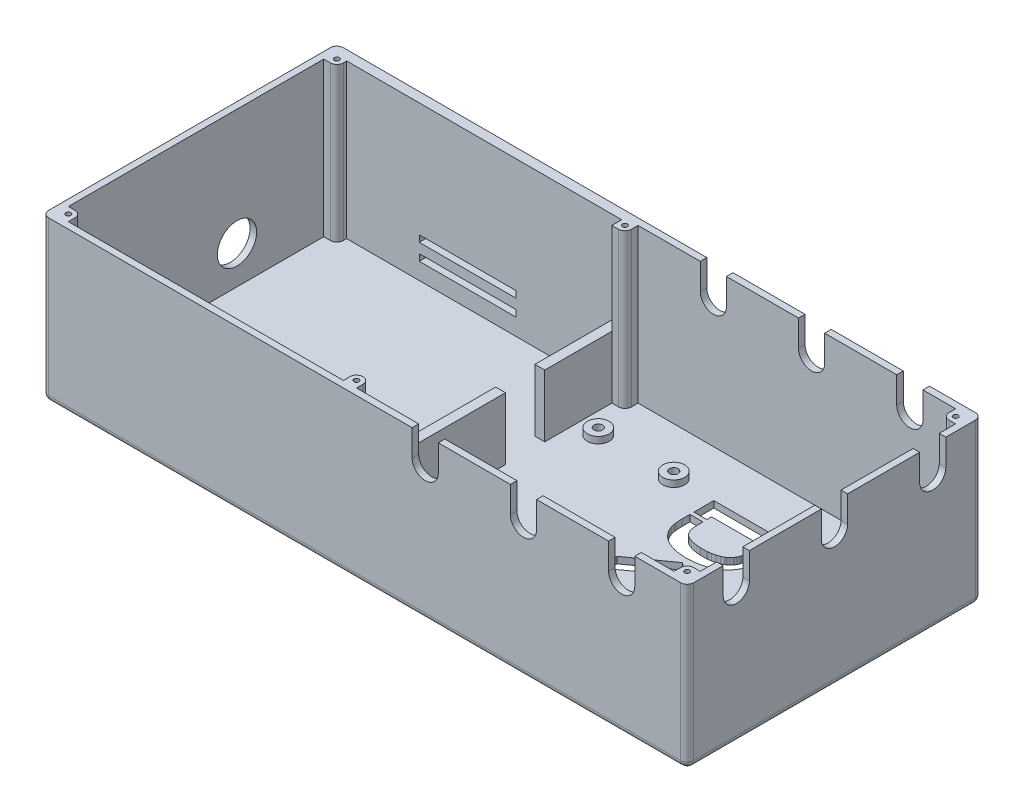
from build123d import *

# Parameters (mm, degrees)
SKETCH2_W               = 197
SKETCH2_H               = 90
BOSS_EXTRUDE1_DEPTH     = 21
SHELL1_T                = -2
SKETCH3_R               = 3.325
SKETCH3_R_2             = 1.325
BOSS_EXTRUDE2_DEPTH     = 2
SKETCH6_R               = 1.325
CUT_EXTRUDE2_DEPTH      = 3
BOSS_EXTRUDE3_DEPTH     = 19
SKETCH10_W              = 3
SKETCH10_H              = 12
CUT_EXTRUDE5_DEPTH      = 19
SKETCH12_W              = 29.592043876
SKETCH12_H              = 2
CUT_EXTRUDE6_DEPTH      = 67.044155007
CUT_EXTRUDE6_DEPTH_BACK = 73
CUT_EXTRUDE8_DEPTH      = 10
FILLET1_R               = 2
SKETCH7_R               = 6
CUT_EXTRUDE9_DEPTH      = 10
BOSS_EXTRUDE4_DEPTH     = 24
SKETCH18_W              = 191
SKETCH18_H              = 84
CUT_EXTRUDE10_DEPTH     = 21
BOSS_EXTRUDE5_DEPTH     = 19
SKETCH22_R              = 0.75
CUT_EXTRUDE11_DEPTH     = 44
SKETCH23_R              = 2
CUT_EXTRUDE12_DEPTH     = 22
SKETCH24_W              = 197
SKETCH24_H              = 24
CUT_EXTRUDE13_DEPTH     = 91
SKETCH25_R              = 0.75
BOSS_EXTRUDE9_DEPTH     = 28
BOSS_EXTRUDE10_START    = -2
BOSS_EXTRUDE10_DEPTH    = 2
BOSS_EXTRUDE11_DEPTH    = 30
SKETCH28_W              = 191
SKETCH28_H              = 84
CUT_EXTRUDE14_DEPTH     = 27
SKETCH29_R              = 0.75
CUT_EXTRUDE15_DEPTH     = 78
SKETCH30_W              = 197
SKETCH30_H              = 30
CUT_EXTRUDE16_DEPTH     = 91
CUT_EXTRUDE17_DEPTH     = 10
CUT_EXTRUDE18_DEPTH     = 91
CUT_EXTRUDE19_DEPTH     = 10


with BuildPart() as part:
    # Sketch2 → Boss-Extrude1 (new body)
    with BuildSketch(Plane(origin=(0, 0, 0), x_dir=(1, 0, 0), z_dir=(0, 1, 0))):
        with Locations((98.5, 45)):
            Rectangle(SKETCH2_W, SKETCH2_H)
    extrude(amount=BOSS_EXTRUDE1_DEPTH)

    # Shell1
    shell1_openings = [part.faces().sort_by_distance(p)[0] for p in [
        (98.5, 21, -45),
    ]]
    offset(amount=SHELL1_T, openings=shell1_openings, kind=Kind.INTERSECTION)

    # Sketch3 → Boss-Extrude2 (add)
    with BuildSketch(Plane(origin=(0.486650368, 2, 38.670182975), x_dir=(1, 0, 0), z_dir=(0, 1, 0))):
        with Locations((118.948969004, 54.089521182)):
            Circle(SKETCH3_R)
        with Locations((118.948969004, 54.089521182)):
            Circle(SKETCH3_R_2, mode=Mode.SUBTRACT)
        with Locations((95.898969004, 54.089521182)):
            Circle(SKETCH3_R)
        with Locations((95.898969004, 54.089521182)):
            Circle(SKETCH3_R_2, mode=Mode.SUBTRACT)
        with Locations((95.898969004, 112.139521182)):
            Circle(SKETCH3_R)
        with Locations((95.898969004, 112.139521182)):
            Circle(SKETCH3_R_2, mode=Mode.SUBTRACT)
        with Locations((118.948969004, 112.139521182)):
            Circle(SKETCH3_R)
        with Locations((118.948969004, 112.139521182)):
            Circle(SKETCH3_R_2, mode=Mode.SUBTRACT)
    extrude(amount=BOSS_EXTRUDE2_DEPTH)

    # Sketch6 → Cut-Extrude2 (cut, through all)
    with BuildSketch(Plane(origin=(0, 2, 0), x_dir=(1, 0, 0), z_dir=(0, 1, 0))):
        with Locations((96.385619372, 73.469338207)):
            Circle(SKETCH6_R)
        with Locations((119.435619372, 73.469338207)):
            Circle(SKETCH6_R)
        with Locations((119.435619372, 15.419338207)):
            Circle(SKETCH6_R)
        with Locations((96.385619372, 15.419338207)):
            Circle(SKETCH6_R)
    extrude(amount=-CUT_EXTRUDE2_DEPTH, mode=Mode.SUBTRACT)

    # Sketch8 → Boss-Extrude3 (add)
    with BuildSketch(Plane(origin=(0, 2, 0), x_dir=(1, 0, 0), z_dir=(0, 1, 0))):
        Polygon((2, 28), (87, 28), (87, 87), (2, 87), (2, 90), (90, 90), (90, 25), (2, 25), align=None)
    extrude(amount=BOSS_EXTRUDE3_DEPTH)

    # Sketch10 → Cut-Extrude5 (cut)
    with BuildSketch(Plane(origin=(0, 21, 0), x_dir=(1, 0, 0), z_dir=(0, 1, 0))):
        with Locations((88.5, 57.5)):
            Rectangle(SKETCH10_W, SKETCH10_H)
    extrude(amount=-CUT_EXTRUDE5_DEPTH, mode=Mode.SUBTRACT)

    # Sketch12 → Cut-Extrude6 (cut, two sides)
    with BuildSketch(Plane(origin=(0, 0, -75), x_dir=(-1, 0, 0), z_dir=(0, 0, -1))) as cut_extrude6_sk:
        with Locations((-42.979341868, 13.109706)):
            Rectangle(SKETCH12_W, SKETCH12_H)
        with Locations((-42.979341868, 8.109706)):
            Rectangle(SKETCH12_W, SKETCH12_H)
    extrude(amount=CUT_EXTRUDE6_DEPTH, mode=Mode.SUBTRACT)
    extrude(cut_extrude6_sk.sketch, amount=-CUT_EXTRUDE6_DEPTH_BACK, mode=Mode.SUBTRACT)

    # Sketch16 → Cut-Extrude8 (cut)
    with BuildSketch(Plane(origin=(197, 0, 0), x_dir=(0, 0, -1), z_dir=(1, 0, 0))):
        with BuildLine():
            Line((48, 14.235547834), (48, 21))
            Line((48, 21), (42, 21))
            Line((42, 21), (42, 14.235547834))
            ThreePointArc((42, 14.235547834), (45, 11.235547834), (48, 14.235547834))
        make_face()
    extrude(amount=-CUT_EXTRUDE8_DEPTH, mode=Mode.SUBTRACT)

    # Fillet1
    fillet1_edges = [part.edges().sort_by_distance(p)[0] for p in [
        (98.5, 0, -90),
        (197, 0, -45),
        (98.5, 0, 0),
        (0, 0, -45),
        (0, 10.5, -90),
        (197, 10.5, -90),
        (197, 10.5, 0),
        (0, 10.5, 0),
    ]]
    fillet(fillet1_edges, radius=FILLET1_R)

    # Sketch7 → Cut-Extrude9 (cut)
    with BuildSketch(Plane.ZY):
        with Locations((-57.5, 13.5)):
            Circle(SKETCH7_R)
    extrude(amount=-CUT_EXTRUDE9_DEPTH, mode=Mode.SUBTRACT)

    # Sketch17 → Boss-Extrude4 (add)
    with BuildSketch(Plane(origin=(0, 21, 0), x_dir=(1, 0, 0), z_dir=(0, 1, 0))):
        with BuildLine():
            Line((197, 48), (197, 42))
            Line((197, 42), (197, 2))
            ThreePointArc((197, 2), (196.414213562, 0.585786438), (195, 0))
            Line((195, 0), (2, 0))
            ThreePointArc((2, 0), (0.585786438, 0.585786438), (0, 2))
            Line((0, 2), (0, 88))
            ThreePointArc((0, 88), (0.585786438, 89.414213562), (2, 90))
            Line((2, 90), (195, 90))
            ThreePointArc((195, 90), (196.414213562, 89.414213562), (197, 88))
            Line((197, 88), (197, 48))
        make_face()
    extrude(amount=BOSS_EXTRUDE4_DEPTH)

    # Sketch18 → Cut-Extrude10 (cut)
    with BuildSketch(Plane(origin=(0, 45, 0), x_dir=(1, 0, 0), z_dir=(0, 1, 0))):
        with Locations((98.5, 45)):
            Rectangle(SKETCH18_W, SKETCH18_H)
    extrude(amount=-CUT_EXTRUDE10_DEPTH, mode=Mode.SUBTRACT)

    # Sketch19 → Boss-Extrude5 (add)
    with BuildSketch(Plane(origin=(0, 2, 0), x_dir=(1, 0, 0), z_dir=(0, 1, 0))):
        with BuildLine():
            Line((193, 88), (195, 88))
            Line((195, 88), (195, 84))
            Line((195, 84), (193, 84))
            ThreePointArc((193, 84), (191.585786438, 84.585786438), (191, 86))
            Line((191, 86), (191, 88))
            Line((191, 88), (193, 88))
        make_face()
        with BuildLine():
            Line((191, 2), (193, 2))
            Line((193, 2), (195, 2))
            Line((195, 2), (195, 6))
            Line((195, 6), (193, 6))
            ThreePointArc((193, 6), (191.585786438, 5.414213562), (191, 4))
            Line((191, 4), (191, 2))
        make_face()
        with BuildLine():
            Line((94, 4), (94, 2))
            Line((94, 2), (90, 2))
            Line((90, 2), (90, 4))
            ThreePointArc((90, 4), (92, 6), (94, 4))
        make_face()
        with BuildLine():
            Line((92, 84), (90, 84))
            Line((90, 84), (90, 88))
            Line((90, 88), (94, 88))
            Line((94, 88), (94, 86))
            ThreePointArc((94, 86), (93.414213562, 84.585786438), (92, 84))
        make_face()
        with BuildLine():
            Line((2, 88), (2, 84))
            Line((2, 84), (4, 84))
            ThreePointArc((4, 84), (5.414213562, 84.585786438), (6, 86))
            Line((6, 86), (6, 88))
            Line((6, 88), (2, 88))
        make_face()
        with BuildLine():
            Line((6, 4), (6, 2))
            Line((6, 2), (2, 2))
            Line((2, 2), (2, 6))
            Line((2, 6), (4, 6))
            ThreePointArc((4, 6), (5.414213562, 5.414213562), (6, 4))
        make_face()
    extrude(amount=BOSS_EXTRUDE5_DEPTH)

    # Sketch22 → Cut-Extrude11 (cut, through all)
    with BuildSketch(Plane(origin=(0, 2, 0), x_dir=(1, 0, 0), z_dir=(0, 1, 0))):
        with Locations((4, 4)):
            Circle(SKETCH22_R)
        with Locations((4, 86)):
            Circle(SKETCH22_R)
        with Locations((92, 86)):
            Circle(SKETCH22_R)
        with Locations((193, 86)):
            Circle(SKETCH22_R)
        with Locations((193, 4)):
            Circle(SKETCH22_R)
        with Locations((92, 4)):
            Circle(SKETCH22_R)
    extrude(amount=CUT_EXTRUDE11_DEPTH, mode=Mode.SUBTRACT)

    # Sketch23 → Cut-Extrude12 (cut, through all)
    with BuildSketch(Plane(origin=(0, 24, 0), x_dir=(1, 0, 0), z_dir=(0, 1, 0))):
        with Locations((92, 4)):
            Circle(SKETCH23_R)
        with Locations((4, 4)):
            Circle(SKETCH23_R)
        with Locations((4, 86)):
            Circle(SKETCH23_R)
        with Locations((92, 86)):
            Circle(SKETCH23_R)
        with Locations((193, 86)):
            Circle(SKETCH23_R)
        with Locations((181, 4)):
            Circle(SKETCH23_R)
    extrude(amount=CUT_EXTRUDE12_DEPTH, mode=Mode.SUBTRACT)

    # Sketch24 → Cut-Extrude13 (cut, through all)
    with BuildSketch(Plane.XY):
        with Locations((98.5, 33)):
            Rectangle(SKETCH24_W, SKETCH24_H)
    extrude(amount=-CUT_EXTRUDE13_DEPTH, mode=Mode.SUBTRACT)

    # Sketch25 → Boss-Extrude9 (add)
    with BuildSketch(Plane(origin=(0, 21, 0), x_dir=(1, 0, 0), z_dir=(0, 1, 0))):
        with BuildLine():
            Line((197, 42), (197, 48))
            Line((197, 48), (197, 88))
            ThreePointArc((197, 88), (196.414213562, 89.414213562), (195, 90))
            Line((195, 90), (2, 90))
            ThreePointArc((2, 90), (0.585786438, 89.414213562), (0, 88))
            Line((0, 88), (0, 2))
            ThreePointArc((0, 2), (0.585786438, 0.585786438), (2, 0))
            Line((2, 0), (195, 0))
            ThreePointArc((195, 0), (196.414213562, 0.585786438), (197, 2))
            Line((197, 2), (197, 42))
        make_face()
        with Locations((4, 4)):
            Circle(SKETCH25_R, mode=Mode.SUBTRACT)
        with Locations((4, 86)):
            Circle(SKETCH25_R, mode=Mode.SUBTRACT)
        with Locations((92, 86)):
            Circle(SKETCH25_R, mode=Mode.SUBTRACT)
        with Locations((193, 86)):
            Circle(SKETCH25_R, mode=Mode.SUBTRACT)
        with Locations((193, 4)):
            Circle(SKETCH25_R, mode=Mode.SUBTRACT)
        with Locations((92, 4)):
            Circle(SKETCH25_R, mode=Mode.SUBTRACT)
        with BuildLine():
            Line((2, 25), (2, 28))
            Line((2, 28), (2, 84))
            Line((2, 84), (4, 84))
            ThreePointArc((4, 84), (5.414213562, 84.585786438), (6, 86))
            Line((6, 86), (6, 87))
            Line((6, 87), (87, 87))
            Line((87, 87), (90, 87))
            Line((90, 87), (90, 84))
            Line((90, 84), (92, 84))
            ThreePointArc((92, 84), (93.414213562, 84.585786438), (94, 86))
            Line((94, 86), (94, 88))
            Line((94, 88), (191, 88))
            Line((191, 88), (191, 86))
            ThreePointArc((191, 86), (191.585786438, 84.585786438), (193, 84))
            Line((193, 84), (195, 84))
            Line((195, 84), (195, 48))
            Line((195, 48), (195, 42))
            Line((195, 42), (195, 6))
            Line((195, 6), (193, 6))
            ThreePointArc((193, 6), (191.585786438, 5.414213562), (191, 4))
            Line((191, 4), (191, 2))
            Line((191, 2), (94, 2))
            Line((94, 2), (94, 4))
            ThreePointArc((94, 4), (92, 6), (90, 4))
            Line((90, 4), (90, 2))
            Line((90, 2), (6, 2))
            Line((6, 2), (6, 4))
            ThreePointArc((6, 4), (5.414213562, 5.414213562), (4, 6))
            Line((4, 6), (2, 6))
            Line((2, 6), (2, 25))
        make_face(mode=Mode.SUBTRACT)
    extrude(amount=BOSS_EXTRUDE9_DEPTH)

    # Sketch26 → Boss-Extrude10 (add)
    with BuildSketch(Plane(origin=(197, 0, 0), x_dir=(0, 0, -1), z_dir=(1, 0, 0)).offset(BOSS_EXTRUDE10_START)):
        with BuildLine():
            Line((48, 21), (42, 21))
            Line((42, 21), (42, 14.235547834))
            ThreePointArc((42, 14.235547834), (45, 11.235547834), (48, 14.235547834))
            Line((48, 14.235547834), (48, 21))
        make_face()
    extrude(amount=BOSS_EXTRUDE10_DEPTH)

    # Sketch27 → Boss-Extrude11 (add)
    with BuildSketch(Plane(origin=(0, 49, 0), x_dir=(1, 0, 0), z_dir=(0, 1, 0))):
        with BuildLine():
            Line((197, 2), (197, 88))
            ThreePointArc((197, 88), (196.414213562, 89.414213562), (195, 90))
            Line((195, 90), (2, 90))
            ThreePointArc((2, 90), (0.585786438, 89.414213562), (0, 88))
            Line((0, 88), (0, 2))
            ThreePointArc((0, 2), (0.585786438, 0.585786438), (2, 0))
            Line((2, 0), (195, 0))
            ThreePointArc((195, 0), (196.414213562, 0.585786438), (197, 2))
        make_face()
    extrude(amount=BOSS_EXTRUDE11_DEPTH)

    # Sketch28 → Cut-Extrude14 (cut)
    with BuildSketch(Plane(origin=(0, 79, 0), x_dir=(1, 0, 0), z_dir=(0, 1, 0))):
        with Locations((98.5, 45)):
            Rectangle(SKETCH28_W, SKETCH28_H)
    extrude(amount=-CUT_EXTRUDE14_DEPTH, mode=Mode.SUBTRACT)

    # Sketch29 → Cut-Extrude15 (cut, through all)
    with BuildSketch(Plane(origin=(0, 2, 0), x_dir=(1, 0, 0), z_dir=(0, 1, 0))):
        with Locations((4, 4)):
            Circle(SKETCH29_R)
        with Locations((4, 86)):
            Circle(SKETCH29_R)
        with Locations((193, 86)):
            Circle(SKETCH29_R)
        with Locations((193, 4)):
            Circle(SKETCH29_R)
        with Locations((92, 4)):
            Circle(SKETCH29_R)
        with Locations((92, 86)):
            Circle(SKETCH29_R)
    extrude(amount=CUT_EXTRUDE15_DEPTH, mode=Mode.SUBTRACT)

    # Sketch30 → Cut-Extrude16 (cut, through all)
    with BuildSketch(Plane.XY):
        with Locations((98.5, 64)):
            Rectangle(SKETCH30_W, SKETCH30_H)
    extrude(amount=-CUT_EXTRUDE16_DEPTH, mode=Mode.SUBTRACT)

    # Sketch31 → Cut-Extrude17 (cut)
    with BuildSketch(Plane(origin=(197, 0, 0), x_dir=(0, 0, -1), z_dir=(1, 0, 0))):
        with BuildLine():
            Line((11, 41), (11, 49))
            Line((11, 49), (19, 49))
            Line((19, 49), (19, 41))
            ThreePointArc((19, 41), (15, 37), (11, 41))
        make_face()
        with BuildLine():
            Line((41, 41), (41, 49))
            Line((41, 49), (49, 49))
            Line((49, 49), (49, 41))
            ThreePointArc((49, 41), (45, 37), (41, 41))
        make_face()
        with BuildLine():
            Line((71, 41), (71, 49))
            Line((71, 49), (79, 49))
            Line((79, 49), (79, 41))
            ThreePointArc((79, 41), (75, 37), (71, 41))
        make_face()
    extrude(amount=-CUT_EXTRUDE17_DEPTH, mode=Mode.SUBTRACT)

    # Sketch32 → Cut-Extrude18 (cut, through all)
    with BuildSketch(Plane(origin=(0, 0, -90), x_dir=(-1, 0, 0), z_dir=(0, 0, -1))):
        with BuildLine():
            Line((-181, 41), (-181, 49))
            Line((-181, 49), (-173, 49))
            Line((-173, 49), (-173, 41))
            ThreePointArc((-173, 41), (-177, 37), (-181, 41))
        make_face()
        with BuildLine():
            Line((-151, 41), (-151, 49))
            Line((-151, 49), (-143, 49))
            Line((-143, 49), (-143, 41))
            ThreePointArc((-143, 41), (-147, 37), (-151, 41))
        make_face()
        with BuildLine():
            Line((-121, 41), (-121, 49))
            Line((-121, 49), (-113, 49))
            Line((-113, 49), (-113, 41))
            ThreePointArc((-113, 41), (-117, 37), (-121, 41))
        make_face()
    extrude(amount=-CUT_EXTRUDE18_DEPTH, mode=Mode.SUBTRACT)

    # Sketch33 → Cut-Extrude19 (cut)
    with BuildSketch(Plane.XZ):
        Polygon((131.342069702, -73.803675328), (154.299866313, -73.803675328), (154.299710305, -67.699378511), (150.316474948, -67.699480311), (150.316313825, -69.149681439), (135.319235293, -69.147777765), (135.319198289, -67.699863597), (131.341230491, -67.699965262), align=None)
        Polygon((131.341196563, -66.484557272), (135.319260846, -66.484557272), (135.34368408, -64.448057478), (135.366792102, -63.9318726), (135.560848598, -62.708661438), (135.682097263, -62.30423458), (135.893678175, -61.80665932), (136.275241305, -61.197101423), (136.768517085, -60.67728932), (137.206412644, -60.358311251), (137.3654264, -60.27696896), (137.619460466, -60.141314863), (138.429329253, -59.821544458), (139.54711523, -59.528585895), (140.695070485, -59.357991654), (141.560104111, -59.285015115), (141.848980484, -59.270014756), (142.00799298, -59.272040737), (142.805194033, -59.265085002), (143.60096036, -59.290522135), (143.759711846, -59.308402947), (144.050981541, -59.329738361), (144.921754504, -59.443760306), (146.067309513, -59.694935945), (147.169553693, -60.084590402), (147.605365412, -60.302115943), (147.957226718, -60.477739539), (148.201945322, -60.636173155), (148.373464392, -60.746984895), (148.849657075, -61.139866676), (149.399162726, -61.749166962), (149.829282509, -62.446458977), (150.066552209, -63.017081808), (150.164389322, -63.370649856), (150.286428528, -64.169287648), (150.317606227, -64.978301492), (150.317340242, -65.139921721), (150.317022102, -65.474177119), (150.316844778, -66.484742951), (154.299866306, -66.484742951), (154.306130009, -63.827777621), (154.309097575, -63.683201339), (154.306130009, -63.623229381), (154.268936568, -62.871581975), (154.116406448, -61.799026946), (153.840444811, -60.752175467), (153.552327203, -59.991431467), (153.435112316, -59.74815528), (153.342480786, -59.558502461), (153.021810637, -59.010084781), (152.530520674, -58.321492203), (151.968210602, -57.68908415), (151.505505487, -57.253614431), (151.341853839, -57.119984458), (151.141228331, -56.954918185), (150.503388934, -56.503551752), (149.605979523, -55.976290307), (148.663300078, -55.532707499), (147.935082309, -55.248985177), (147.688602595, -55.166804833), (147.604867631, -55.139298477), (147.350303253, -55.055675841), (146.313807779, -54.788724896), (144.910815347, -54.539325507), (143.490748225, -54.407398012), (142.421835999, -54.374506132), (141.873394291, -54.376795695), (140.474075853, -54.480053515), (139.960962127, -54.536392347), (139.679215442, -54.574485676), (138.769173961, -54.740147845), (138.678843121, -54.759836004), (138.345808129, -54.826175974), (137.364112179, -55.111912445), (136.106036197, -55.63316624), (134.930157627, -56.318115995), (134.112525325, -56.932308332), (133.862219717, -57.161228166), (133.621489595, -57.382596091), (132.982823964, -58.13649352), (132.29180869, -59.251135395), (131.797688048, -60.467712388), (131.554081629, -61.424515204), (131.497799571, -61.801701219), (131.409218501, -62.50048484), (131.341071393, -64.081483142), align=None)
        Polygon((142.953556674, -52.556580272), (154.299866306, -44.616332617), (154.301274465, -38.429108229), (142.974890294, -46.718522128), (131.343451785, -38.174815443), (131.34127696, -44.295226976), align=None)
        Polygon((135.402185367, -35.845823553), (131.34127696, -35.845557567), (131.342601674, -16.394840147), (135.403572665, -16.394840147), align=None)
        Polygon((140.913545238, -35.845291581), (140.913545238, -16.394840147), (144.982605325, -16.397500005), (144.981113719, -35.843163695), align=None)
        Polygon((150.225835936, -35.845291581), (150.225835936, -16.394840147), (154.306130009, -16.394840147), (154.306130009, -35.845557567), align=None)
    extrude(amount=-CUT_EXTRUDE19_DEPTH, mode=Mode.SUBTRACT)


solid = part.part
